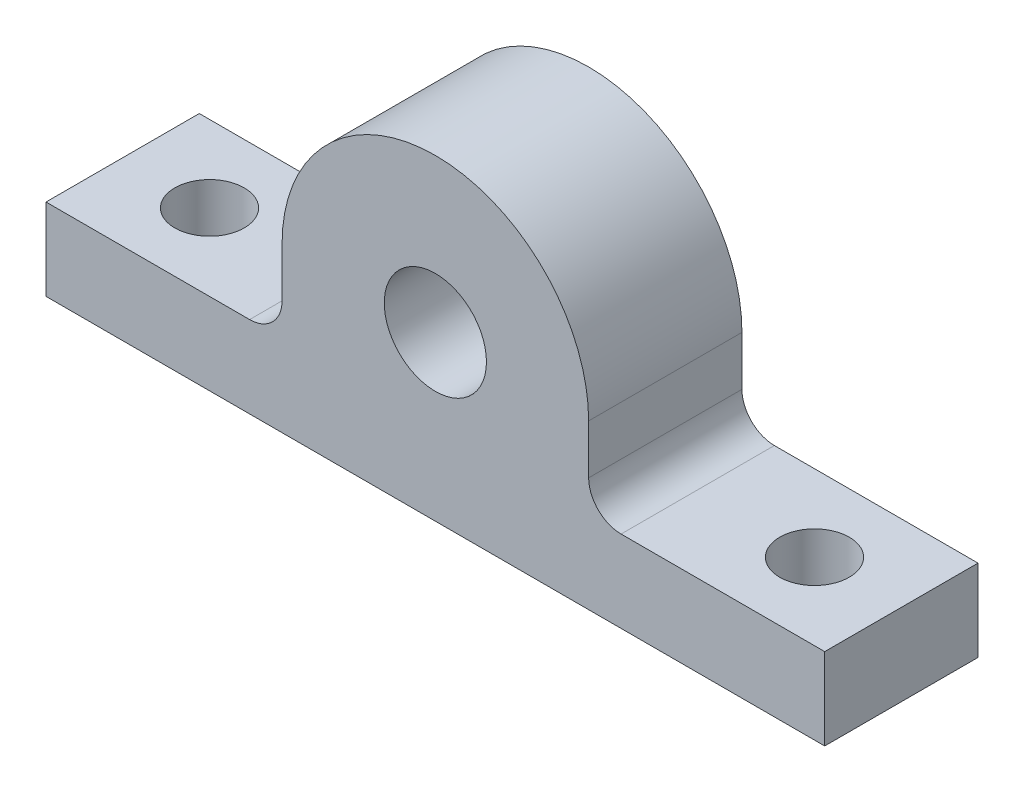
from build123d import *

# Parameters (mm, degrees)
SKETCH1_R                        = 5
BOSS_EXTRUDE1_DEPTH              = 15
FILLET1_R                        = 3.175
TAP_DRILL_FOR_M8X1_25_TAP1_D     = 6.8
TAP_DRILL_FOR_M8X1_25_TAP1_DEPTH = 20
TAP_DRILL_FOR_M8X1_25_TAP1_TIP   = 2.042926105


with BuildPart() as part:
    # Sketch1 → Boss-Extrude1 (new body)
    with BuildSketch(Plane.XY):
        with BuildLine():
            Line((-38.1, 4), (-38.1, -4))
            Line((-38.1, -4), (38.1, -4))
            Line((38.1, -4), (38.1, 4))
            Line((38.1, 4), (15, 4))
            Line((15, 4), (15, 12))
            ThreePointArc((15, 12), (0, 27), (-15, 12))
            Line((-15, 12), (-15, 4))
            Line((-15, 4), (-38.1, 4))
        make_face()
        with Locations((0, 12)):
            Circle(SKETCH1_R, mode=Mode.SUBTRACT)
    extrude(amount=BOSS_EXTRUDE1_DEPTH)

    # Fillet1
    fillet1_edges = [part.edges().sort_by_distance(p)[0] for p in [
        (15, 4, 7.5),
        (-15, 4, 7.5),
    ]]
    fillet(fillet1_edges, radius=FILLET1_R)

    # Tap Drill for M8x1.25 Tap1
    with Locations(Plane(origin=(0, 4, 0), x_dir=(1, 0, 0), z_dir=(0, 1, 0))):
        with Locations((29.6, -7.5), (-29.6, -7.5)):
            Hole(TAP_DRILL_FOR_M8X1_25_TAP1_D / 2, depth=TAP_DRILL_FOR_M8X1_25_TAP1_DEPTH)
            with Locations((0, 0, -(TAP_DRILL_FOR_M8X1_25_TAP1_DEPTH + TAP_DRILL_FOR_M8X1_25_TAP1_TIP / 2))):  # 118° drill point
                Cone(0, TAP_DRILL_FOR_M8X1_25_TAP1_D / 2, TAP_DRILL_FOR_M8X1_25_TAP1_TIP, mode=Mode.SUBTRACT)


solid = part.part
